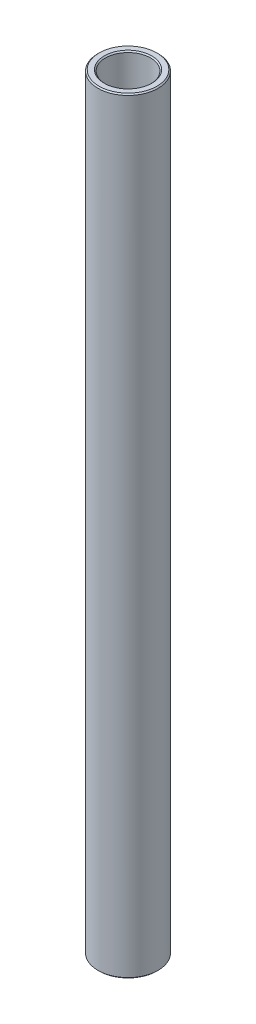
from build123d import *

# Parameters (mm, degrees)
SKETCH1_W     = 1.5875
SKETCH1_H     = 161.737331671
CHAMFER1_SIZE = 0.254


with BuildPart() as part:
    # Sketch1 → Revolve1 (revolve)
    with BuildSketch(Plane.XY):
        with Locations((5.55625, 205.12785438)):
            Rectangle(SKETCH1_W, SKETCH1_H)
    revolve(axis=Axis((0, 114.734188544, 0), (0, 1, 0)))

    # Chamfer1
    chamfer1_edges = [part.edges().sort_by_distance(p)[0] for p in [
        (-6.35, 124.259188544, 0),
        (-6.349999999, 285.996520215, 0),
        (-4.762499999, 285.996520215, 0),
        (-4.7625, 124.259188544, 0),
    ]]
    chamfer(chamfer1_edges, length=CHAMFER1_SIZE)


solid = part.part
